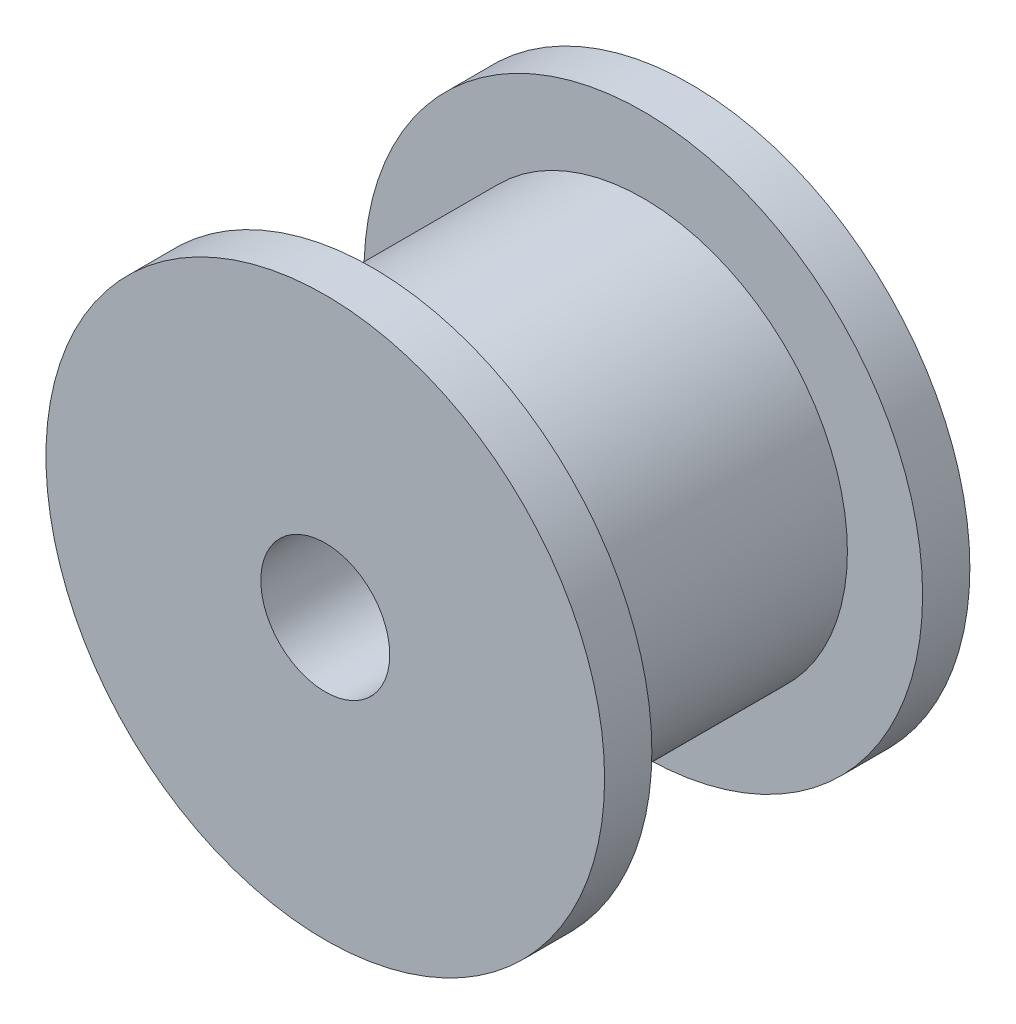
from build123d import *

# Parameters (mm, degrees)
SKETCH_1_R          = 6.5
EXTRUDE_1_DEPTH     = 8.5
SKETCH_2_R          = 1.5
CUT_EXTRUDE_1_DEPTH = 10
SKETCH_3_R          = 9
SKETCH_3_R_2        = 4.75
CUT_EXTRUDE_2_DEPTH = 6.3


with BuildPart() as part:
    # 草图1 → 凸台-拉伸1 (new body)
    with BuildSketch(Plane.XY):
        Circle(SKETCH_1_R)
    extrude(amount=EXTRUDE_1_DEPTH)

    # 草图2 → 切除-拉伸1 (cut)
    with BuildSketch(Plane.XY.offset(8.5)):
        Circle(SKETCH_2_R)
    extrude(amount=-CUT_EXTRUDE_1_DEPTH, mode=Mode.SUBTRACT)

    # 草图3 → 切除-拉伸2 (cut)
    with BuildSketch(Plane.XY.offset(7.4)):
        Circle(SKETCH_3_R)
        Circle(SKETCH_3_R_2, mode=Mode.SUBTRACT)
    extrude(amount=-CUT_EXTRUDE_2_DEPTH, mode=Mode.SUBTRACT)


solid = part.part
